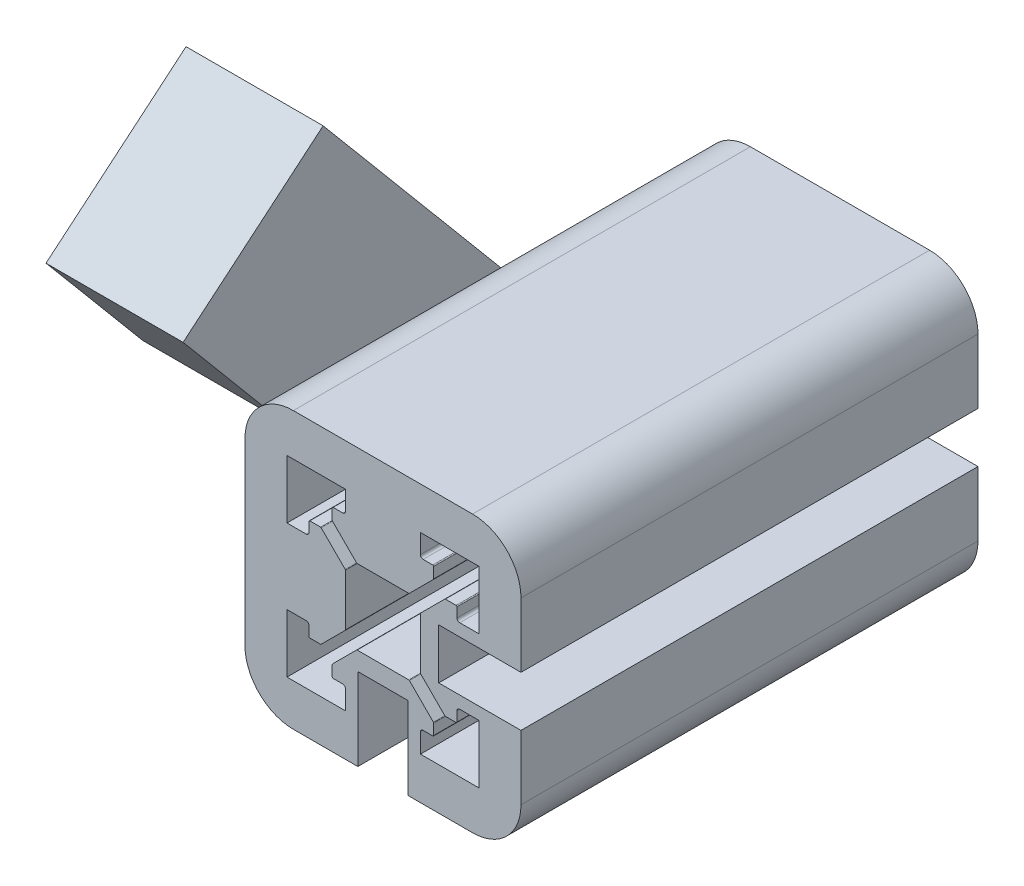
from build123d import *

# Parameters (mm, degrees)
Y_KSEKLIK_EKSTR_ZYON3_DEPTH = 25
Y_KSEKLIK_EKSTR_ZYON4_DEPTH = 15
IZIM11_R                    = 3.5
KES_EKSTR_ZYON3_DEPTH       = 10
KES_EKSTR_ZYON4_DEPTH       = 16
KES_EKSTR_ZYON5_REACH       = 77.444


with BuildPart() as part:
    # Çizim6 → Yükseklik-Ekstrüzyon3 (new, symmetric)
    with BuildSketch(Plane.XY):
        with BuildLine():
            Line((-119.371512251, 18.973770729), (-115.371512251, 18.973770729))
            Line((-115.371512251, 18.973770729), (-110.371512251, 18.973770729))
            Line((-110.371512251, 18.973770729), (-110.371512251, 20.773770729))
            Line((-110.371512251, 20.773770729), (-110.371512251, 26.023770729))
            ThreePointArc((-110.371512251, 26.023770729), (-111.92384631, 29.771436669), (-115.671512251, 31.323770729))
            Line((-115.671512251, 31.323770729), (-120.921512251, 31.323770729))
            Line((-120.921512251, 31.323770729), (-122.721512251, 31.323770729))
            Line((-122.721512251, 31.323770729), (-128.221512251, 31.323770729))
            Line((-128.221512251, 31.323770729), (-130.021512251, 31.323770729))
            Line((-130.021512251, 31.323770729), (-135.271512251, 31.323770729))
            ThreePointArc((-135.271512251, 31.323770729), (-139.019178191, 29.771436669), (-140.571512251, 26.023770729))
            Line((-140.571512251, 26.023770729), (-140.571512251, 20.773770729))
            Line((-140.571512251, 20.773770729), (-140.571512251, 16.223770729))
            Line((-140.571512251, 16.223770729), (-140.571512251, 11.673770729))
            Line((-140.571512251, 11.673770729), (-140.571512251, 6.423770729))
            ThreePointArc((-140.571512251, 6.423770729), (-139.019178191, 2.676104789), (-135.271512251, 1.123770729))
            Line((-135.271512251, 1.123770729), (-130.021512251, 1.123770729))
            Line((-130.021512251, 1.123770729), (-128.221512251, 1.123770729))
            Line((-128.221512251, 1.123770729), (-128.221512251, 6.123770729))
            Line((-128.221512251, 6.123770729), (-128.221512251, 10.123770729))
            Line((-128.221512251, 10.123770729), (-122.721512251, 10.123770729))
            Line((-122.721512251, 10.123770729), (-122.721512251, 6.123770729))
            Line((-122.721512251, 6.123770729), (-122.721512251, 1.123770729))
            Line((-122.721512251, 1.123770729), (-120.921512251, 1.123770729))
            Line((-120.921512251, 1.123770729), (-115.671512251, 1.123770729))
            ThreePointArc((-115.671512251, 1.123770729), (-111.92384631, 2.676104789), (-110.371512251, 6.423770729))
            Line((-110.371512251, 6.423770729), (-110.371512251, 11.673770729))
            Line((-110.371512251, 11.673770729), (-110.371512251, 13.473770729))
            Line((-110.371512251, 13.473770729), (-115.371512251, 13.473770729))
            Line((-115.371512251, 13.473770729), (-119.371512251, 13.473770729))
            Line((-119.371512251, 13.473770729), (-119.371512251, 18.973770729))
        make_face()
        with BuildLine():
            Line((-133.871512251, 20.323770729), (-135.071512251, 20.323770729))
            Line((-135.071512251, 20.323770729), (-135.871512251, 20.323770729))
            Line((-135.871512251, 20.323770729), (-135.971512251, 20.323770729))
            Line((-135.971512251, 20.323770729), (-135.971512251, 26.723770729))
            Line((-135.971512251, 26.723770729), (-129.571512251, 26.723770729))
            Line((-129.571512251, 26.723770729), (-129.571512251, 26.623770729))
            Line((-129.571512251, 26.623770729), (-129.571512251, 25.823770729))
            Line((-129.571512251, 25.823770729), (-129.571512251, 24.623770729))
            ThreePointArc((-129.571512251, 24.623770729), (-129.659380216, 24.411638694), (-129.871512251, 24.323770729))
            Line((-129.871512251, 24.323770729), (-130.921512251, 24.323770729))
            ThreePointArc((-130.921512251, 24.323770729), (-130.992222929, 24.294481407), (-131.021512251, 24.223770729))
            Line((-131.021512251, 24.223770729), (-131.021512251, 23.056613441))
            ThreePointArc((-131.021512251, 23.056613441), (-131.013900204, 23.018345098), (-130.992222929, 22.985902763))
            Line((-130.992222929, 22.985902763), (-128.359380216, 20.353060051))
            ThreePointArc((-128.359380216, 20.353060051), (-128.326937882, 20.331382776), (-128.288669538, 20.323770729))
            Line((-128.288669538, 20.323770729), (-122.654354963, 20.323770729))
            ThreePointArc((-122.654354963, 20.323770729), (-122.61608662, 20.331382776), (-122.583644285, 20.353060051))
            Line((-122.583644285, 20.353060051), (-119.950801573, 22.985902763))
            ThreePointArc((-119.950801573, 22.985902763), (-119.929124298, 23.018345098), (-119.921512251, 23.056613441))
            Line((-119.921512251, 23.056613441), (-119.921512251, 24.223770729))
            ThreePointArc((-119.921512251, 24.223770729), (-119.950801573, 24.294481407), (-120.021512251, 24.323770729))
            Line((-120.021512251, 24.323770729), (-121.071512251, 24.323770729))
            ThreePointArc((-121.071512251, 24.323770729), (-121.283644285, 24.411638694), (-121.371512251, 24.623770729))
            Line((-121.371512251, 24.623770729), (-121.371512251, 25.823770729))
            Line((-121.371512251, 25.823770729), (-121.371512251, 26.323770729))
            Line((-121.371512251, 26.323770729), (-121.371512251, 26.723770729))
            Line((-121.371512251, 26.723770729), (-114.971512251, 26.723770729))
            Line((-114.971512251, 26.723770729), (-114.971512251, 20.323770729))
            Line((-114.971512251, 20.323770729), (-115.371512251, 20.323770729))
            Line((-115.371512251, 20.323770729), (-115.871512251, 20.323770729))
            Line((-115.871512251, 20.323770729), (-117.071512251, 20.323770729))
            ThreePointArc((-117.071512251, 20.323770729), (-117.283644285, 20.411638694), (-117.371512251, 20.623770729))
            Line((-117.371512251, 20.623770729), (-117.371512251, 21.673770729))
            ThreePointArc((-117.371512251, 21.673770729), (-117.400801573, 21.744481407), (-117.471512251, 21.773770729))
            Line((-117.471512251, 21.773770729), (-118.638669538, 21.773770729))
            ThreePointArc((-118.638669538, 21.773770729), (-118.676937882, 21.766158682), (-118.709380216, 21.744481407))
            Line((-118.709380216, 21.744481407), (-121.342222929, 19.111638694))
            ThreePointArc((-121.342222929, 19.111638694), (-121.363900204, 19.07919636), (-121.371512251, 19.040928016))
            Line((-121.371512251, 19.040928016), (-121.371512251, 13.406613441))
            ThreePointArc((-121.371512251, 13.406613441), (-121.363900204, 13.368345098), (-121.342222929, 13.335902763))
            Line((-121.342222929, 13.335902763), (-118.709380216, 10.703060051))
            ThreePointArc((-118.709380216, 10.703060051), (-118.676937882, 10.681382776), (-118.638669538, 10.673770729))
            Line((-118.638669538, 10.673770729), (-117.471512251, 10.673770729))
            ThreePointArc((-117.471512251, 10.673770729), (-117.400801573, 10.703060051), (-117.371512251, 10.773770729))
            Line((-117.371512251, 10.773770729), (-117.371512251, 11.823770729))
            ThreePointArc((-117.371512251, 11.823770729), (-117.283644285, 12.035902763), (-117.071512251, 12.123770729))
            Line((-117.071512251, 12.123770729), (-115.871512251, 12.123770729))
            Line((-115.871512251, 12.123770729), (-115.371512251, 12.123770729))
            Line((-115.371512251, 12.123770729), (-114.971512251, 12.123770729))
            Line((-114.971512251, 12.123770729), (-114.971512251, 5.723770729))
            Line((-114.971512251, 5.723770729), (-121.371512251, 5.723770729))
            Line((-121.371512251, 5.723770729), (-121.371512251, 6.123770729))
            Line((-121.371512251, 6.123770729), (-121.371512251, 6.623770729))
            Line((-121.371512251, 6.623770729), (-121.371512251, 7.823770729))
            ThreePointArc((-121.371512251, 7.823770729), (-121.283644285, 8.035902763), (-121.071512251, 8.123770729))
            Line((-121.071512251, 8.123770729), (-120.021512251, 8.123770729))
            ThreePointArc((-120.021512251, 8.123770729), (-119.950801573, 8.153060051), (-119.921512251, 8.223770729))
            Line((-119.921512251, 8.223770729), (-119.921512251, 9.390928016))
            ThreePointArc((-119.921512251, 9.390928016), (-119.929124298, 9.42919636), (-119.950801573, 9.461638694))
            Line((-119.950801573, 9.461638694), (-122.583644285, 12.094481407))
            ThreePointArc((-122.583644285, 12.094481407), (-122.61608662, 12.116158682), (-122.654354963, 12.123770729))
            Line((-122.654354963, 12.123770729), (-128.288669538, 12.123770729))
            ThreePointArc((-128.288669538, 12.123770729), (-128.326937882, 12.116158682), (-128.359380216, 12.094481407))
            Line((-128.359380216, 12.094481407), (-130.992222929, 9.461638694))
            ThreePointArc((-130.992222929, 9.461638694), (-131.013900204, 9.42919636), (-131.021512251, 9.390928016))
            Line((-131.021512251, 9.390928016), (-131.021512251, 8.223770729))
            ThreePointArc((-131.021512251, 8.223770729), (-130.992222929, 8.153060051), (-130.921512251, 8.123770729))
            Line((-130.921512251, 8.123770729), (-129.871512251, 8.123770729))
            ThreePointArc((-129.871512251, 8.123770729), (-129.659380216, 8.035902763), (-129.571512251, 7.823770729))
            Line((-129.571512251, 7.823770729), (-129.571512251, 6.623770729))
            Line((-129.571512251, 6.623770729), (-129.571512251, 6.123770729))
            Line((-129.571512251, 6.123770729), (-129.571512251, 5.723770729))
            Line((-129.571512251, 5.723770729), (-135.971512251, 5.723770729))
            Line((-135.971512251, 5.723770729), (-135.971512251, 12.123770729))
            Line((-135.971512251, 12.123770729), (-135.571512251, 12.123770729))
            Line((-135.571512251, 12.123770729), (-135.071512251, 12.123770729))
            Line((-135.071512251, 12.123770729), (-133.871512251, 12.123770729))
            ThreePointArc((-133.871512251, 12.123770729), (-133.659380216, 12.035902763), (-133.571512251, 11.823770729))
            Line((-133.571512251, 11.823770729), (-133.571512251, 10.773770729))
            ThreePointArc((-133.571512251, 10.773770729), (-133.542222929, 10.703060051), (-133.471512251, 10.673770729))
            Line((-133.471512251, 10.673770729), (-132.304354963, 10.673770729))
            ThreePointArc((-132.304354963, 10.673770729), (-132.26608662, 10.681382776), (-132.233644285, 10.703060051))
            Line((-132.233644285, 10.703060051), (-129.600801573, 13.335902763))
            ThreePointArc((-129.600801573, 13.335902763), (-129.579124298, 13.368345098), (-129.571512251, 13.406613441))
            Line((-129.571512251, 13.406613441), (-129.571512251, 19.040928016))
            ThreePointArc((-129.571512251, 19.040928016), (-129.579124298, 19.07919636), (-129.600801573, 19.111638694))
            Line((-129.600801573, 19.111638694), (-132.233644285, 21.744481407))
            ThreePointArc((-132.233644285, 21.744481407), (-132.26608662, 21.766158682), (-132.304354963, 21.773770729))
            Line((-132.304354963, 21.773770729), (-133.471512251, 21.773770729))
            ThreePointArc((-133.471512251, 21.773770729), (-133.542222929, 21.744481407), (-133.571512251, 21.673770729))
            Line((-133.571512251, 21.673770729), (-133.571512251, 20.623770729))
            ThreePointArc((-133.571512251, 20.623770729), (-133.659380216, 20.411638694), (-133.871512251, 20.323770729))
        make_face(mode=Mode.SUBTRACT)
    extrude(amount=Y_KSEKLIK_EKSTR_ZYON3_DEPTH, both=True)

    # Çizim8 → Yükseklik-Ekstrüzyon4 (add)
    with BuildSketch(Plane.ZY.offset(140.571512251)):
        Polygon((4.830896508, 6.423770729), (-21.277249279, 6.423770729), (-31.764979794, -6.075019791), (-16.444090932, -18.930771985), align=None)
        Polygon((21.277249279, 26.023770729), (-4.830896508, 26.023770729), (-21.277249279, 6.423770729), (4.830896508, 6.423770729), align=None)
        Polygon((31.764979794, 38.522561249), (16.444090932, 51.378313443), (-4.830896508, 26.023770729), (21.277249279, 26.023770729), align=None)
    extrude(amount=Y_KSEKLIK_EKSTR_ZYON4_DEPTH)

    # Çizim11 → Kes-Ekstrüzyon3 (cut)
    with BuildSketch(Plane.ZY.offset(155.571512251)):
        with Locations(Location((17.998053071, 37.673015136, 0), (0, 0, 270))):
            Circle(IZIM11_R)
        with Locations(Location((-17.998053071, -5.225473678, 0), (0, 0, 270))):
            Circle(IZIM11_R)
    extrude(amount=-KES_EKSTR_ZYON3_DEPTH, mode=Mode.SUBTRACT)

    # Çizim12 → Kes-Ekstrüzyon4 (cut)
    with BuildSketch(Plane(origin=(0, 13.13114735, -15.64909203), x_dir=(1, 0, 0), z_dir=(-3.3982743057988596e-15, 0.6427876096865348, -0.7660444431189819))):
        Polygon((-142.571512251, 23.071870587), (-153.571512251, 23.071870587), (-153.571512251, -47.928129413), (-142.571512251, -47.928129413), (-142.571512251, -16.830124537), (-142.571512251, 8.755858334), align=None)
    extrude(amount=-KES_EKSTR_ZYON4_DEPTH, mode=Mode.SUBTRACT)

    # Kes-Ekstrüzyon5: up to this face of the body (flat: up to its plane)
    kes_ekstr_zyon5_end = Plane(part.part.faces().sort_by_distance((-142.571512251, 17.509345948, -1.532088886))[0])
    # Çizim13 → Kes-Ekstrüzyon5 (cut, up to the picked face)
    with BuildSketch(Plane.ZY.offset(155.571512251), mode=Mode.PRIVATE) as kes_ekstr_zyon5_sk1:
        Polygon((-21.158984235, 6.56471352), (-5.838095372, -6.291038674), (21.158984235, 25.882827937), (5.838095372, 38.738580131), align=None)
    kes_ekstr_zyon5_tool1 = split(extrude(kes_ekstr_zyon5_sk1.sketch, amount=-KES_EKSTR_ZYON5_REACH, mode=Mode.PRIVATE), bisect_by=kes_ekstr_zyon5_end, keep=Keep.BOTH, mode=Mode.PRIVATE)
    add(kes_ekstr_zyon5_tool1.solids().sort_by(Axis((-155.571512, 16.223771, 0), (1, 0, 0)))[0], mode=Mode.SUBTRACT)


solid = part.part
